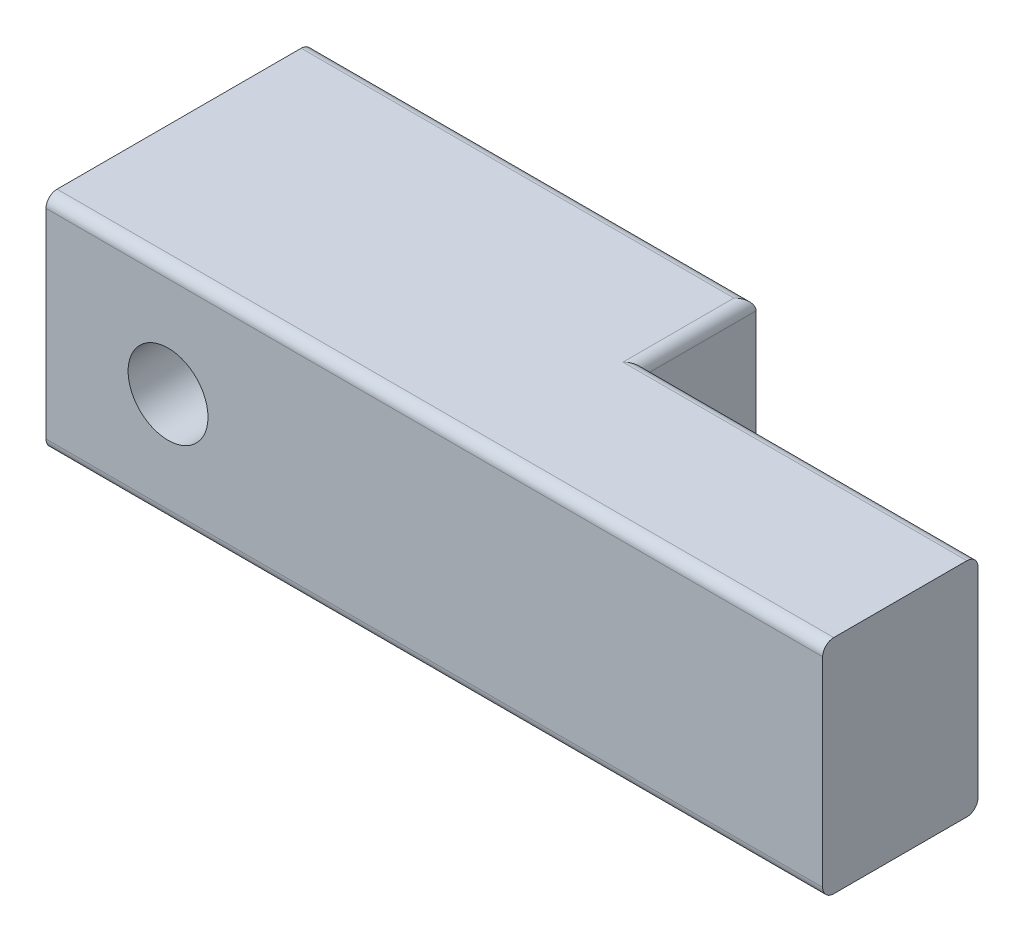
from build123d import *

# Parameters (mm, degrees)
SKETCH1_W                  = 35
SKETCH1_H                  = 10
BOSS_EXTRUDE1_DEPTH        = 7
SKETCH2_W                  = 20
SKETCH2_H                  = 10
BOSS_EXTRUDE2_DEPTH        = 5
FILLET1_R                  = 0.5
F_3_6_3_6_DIAMETER_HOLE1_D = 3.6


with BuildPart() as part:
    # Sketch1 → Boss-Extrude1 (new body)
    with BuildSketch(Plane.XY):
        Rectangle(SKETCH1_W, SKETCH1_H)
    extrude(amount=BOSS_EXTRUDE1_DEPTH)

    # Sketch2 → Boss-Extrude2 (add)
    with BuildSketch(Plane(origin=(0, 0, 0), x_dir=(-1, 0, 0), z_dir=(0, 0, -1))):
        with Locations((7.5, 0)):
            Rectangle(SKETCH2_W, SKETCH2_H)
    extrude(amount=BOSS_EXTRUDE2_DEPTH)

    # Fillet1
    fillet1_edges = [part.edges().sort_by_distance(p)[0] for p in [
        (10, -5, 0),
        (2.5, 5, -2.5),
        (2.5, -5, -2.5),
        (0, -5, 7),
        (-7.5, 5, -5),
        (-7.5, -5, -5),
        (10, 5, 0),
        (0, 5, 7),
    ]]
    fillet(fillet1_edges, radius=FILLET1_R)

    # Ø3.6 (3.6) Diameter Hole1 (through all)
    with Locations(Plane(origin=(-12, 0, 7), x_dir=(1, 0, 0), z_dir=(0, 0, 1))):
        with Locations((0, 0)):
            Hole(F_3_6_3_6_DIAMETER_HOLE1_D / 2)


solid = part.part
